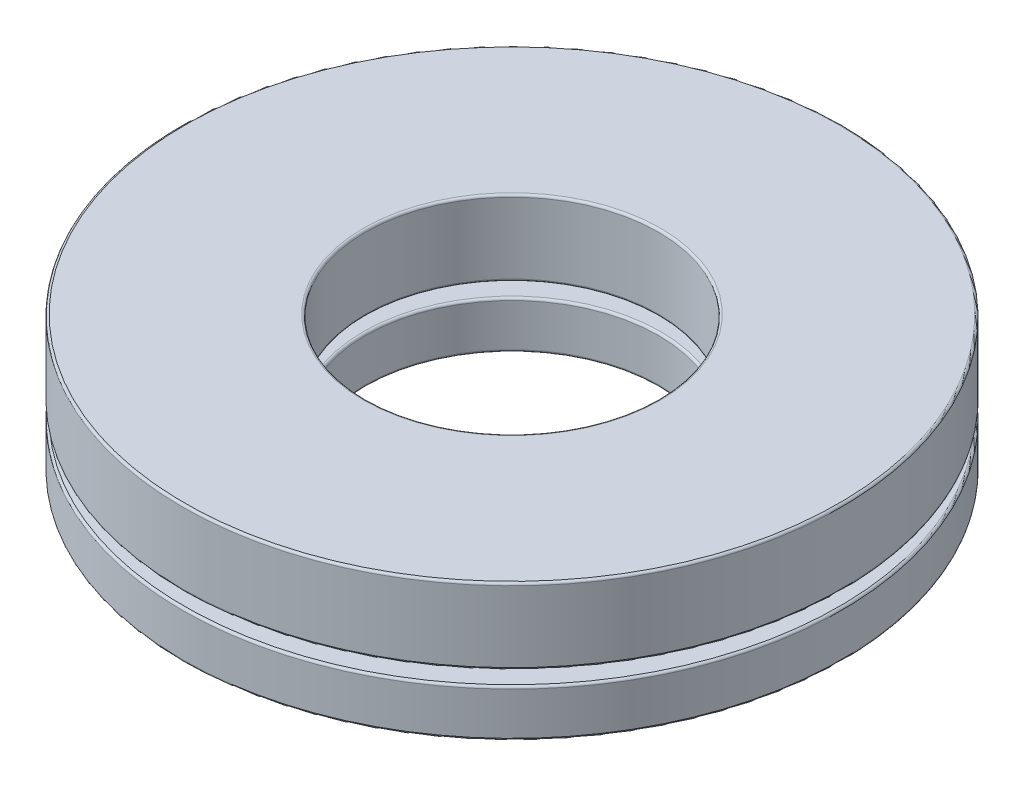
from build123d import *

# Parameters (mm, degrees)
SKETCH1_W         = 3.96875
SKETCH1_H         = 1.021291666
CIRPATTERN1_COUNT = 7
CIRPATTERN1_ANGLE = 308.571428571
CIRPATTERN2_COUNT = 7
SKETCH4_W         = 3.96875
SKETCH4_H         = 1.634066667
FILLET1_R         = 0.049022
FILLET2_R         = 0.049022


with BuildPart() as part:
    # Sketch1 → Revolve1 (revolve)
    with BuildSketch(Plane(origin=(0, 0, 0), x_dir=(0, 0, -1), z_dir=(1, 0, 0))):
        with Locations((-5.159375, 0)):
            Rectangle(SKETCH1_W, SKETCH1_H)
    revolve(axis=Axis((0, -2.4511, 0), (0, 1, 0)))

    # Sketch3 → Cut-Revolve1 (revolve, cut)
    with BuildSketch(Plane(origin=(0, 0, 0), x_dir=(0, 0, -1), z_dir=(1, 0, 0))):
        with BuildLine():
            Line((-5.159375, 0.817033333), (-5.159375, -0.817033333))
            ThreePointArc((-5.159375, -0.817033333), (-5.976408333, 0), (-5.159375, 0.817033333))
        make_face()
    cut_revolve1 = revolve(axis=Axis((0, 0.817033333, 5.159375), (0, -1, 0)), mode=Mode.SUBTRACT)

    # CirPattern2: Cut-Revolve1 ×7 about axis
    cirpattern2_axis = Axis((0, 0, 0), (0, 1, 0))
    for i in range(1, CIRPATTERN2_COUNT):
        add(cut_revolve1.rotate(cirpattern2_axis, i * 360 / CIRPATTERN2_COUNT), mode=Mode.SUBTRACT)

    # Fillet2
    fillet2_edges = [part.edges().sort_by_distance(p)[0] for p in [
        (0, 0.510645833, -7.14375),
        (0, 0.510645833, -3.175),
        (0, -0.510645833, -3.175),
        (0, -0.510645833, -7.14375),
    ]]
    fillet(fillet2_edges, radius=FILLET2_R)


with BuildPart() as body_2:
    # Sketch2 → Revolve2 (revolve)
    with BuildSketch(Plane(origin=(0, 0, 0), x_dir=(0, 0, -1), z_dir=(1, 0, 0))):
        with BuildLine():
            Line((-5.159375, 0.817033333), (-5.159375, -0.817033333))
            ThreePointArc((-5.159375, -0.817033333), (-5.976408333, 0), (-5.159375, 0.817033333))
        make_face()
    revolve(axis=Axis((0, 0.817033333, 5.159375), (0, -1, 0)))


with BuildPart() as cirpattern1_1:
    # CirPattern1: pattern copy
    add(body_2.part.rotate(Axis((0, 2.4511, 0), (0, -1, 0)), 1 * CIRPATTERN1_ANGLE / (CIRPATTERN1_COUNT - 1)))


with BuildPart() as cirpattern1_2:
    # CirPattern1: pattern copy
    add(body_2.part.rotate(Axis((0, 2.4511, 0), (0, -1, 0)), 2 * CIRPATTERN1_ANGLE / (CIRPATTERN1_COUNT - 1)))


with BuildPart() as cirpattern1_3:
    # CirPattern1: pattern copy
    add(body_2.part.rotate(Axis((0, 2.4511, 0), (0, -1, 0)), 3 * CIRPATTERN1_ANGLE / (CIRPATTERN1_COUNT - 1)))


with BuildPart() as cirpattern1_4:
    # CirPattern1: pattern copy
    add(body_2.part.rotate(Axis((0, 2.4511, 0), (0, -1, 0)), 4 * CIRPATTERN1_ANGLE / (CIRPATTERN1_COUNT - 1)))


with BuildPart() as cirpattern1_5:
    # CirPattern1: pattern copy
    add(body_2.part.rotate(Axis((0, 2.4511, 0), (0, -1, 0)), 5 * CIRPATTERN1_ANGLE / (CIRPATTERN1_COUNT - 1)))


with BuildPart() as cirpattern1_6:
    # CirPattern1: pattern copy
    add(body_2.part.rotate(Axis((0, 2.4511, 0), (0, -1, 0)), 6 * CIRPATTERN1_ANGLE / (CIRPATTERN1_COUNT - 1)))


with BuildPart() as body_9:
    # Sketch4 → Revolve3 (revolve)
    with BuildSketch(Plane(origin=(0, 0, 0), x_dir=(0, 0, -1), z_dir=(1, 0, 0))):
        with Locations((-5.159375, 1.634066667)):
            Rectangle(SKETCH4_W, SKETCH4_H)
    revolve(axis=Axis((0, -2.4511, 0), (0, 1, 0)))

    # Fillet1
    fillet1_edges = [body_9.edges().sort_by_distance(p)[0] for p in [
        (0, 0.817033333, -7.14375),
        (0, 0.817033333, -3.175),
        (0, 2.4511, -3.175),
        (0, 2.4511, -7.14375),
    ]]
    fillet(fillet1_edges, radius=FILLET1_R)


solid = Compound([part.part, body_2.part, cirpattern1_1.part, cirpattern1_2.part, cirpattern1_3.part, cirpattern1_4.part, cirpattern1_5.part, cirpattern1_6.part, body_9.part])
